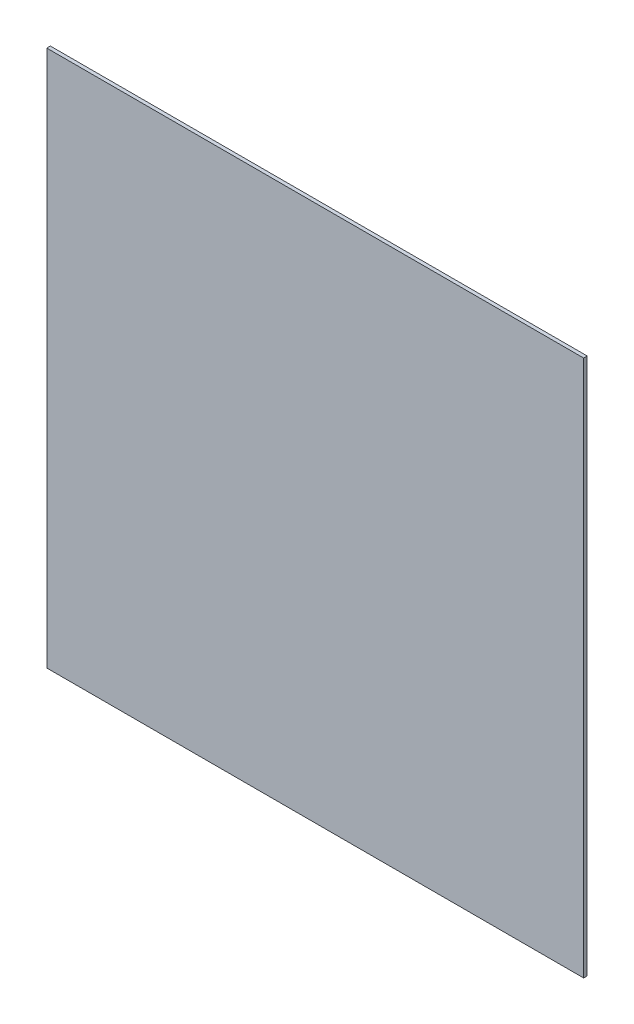
from build123d import *

# Parameters (mm, degrees)
MODEL_W             = 450
MODEL_H             = 450
BOSS_EXTRUDE1_DEPTH = 3


with BuildPart() as part:
    # Model → Boss-Extrude1 (new body)
    with BuildSketch(Plane.XY):
        with Locations((-59.009637129, -17.032423747)):
            Rectangle(MODEL_W, MODEL_H)
    extrude(amount=BOSS_EXTRUDE1_DEPTH)


solid = part.part
